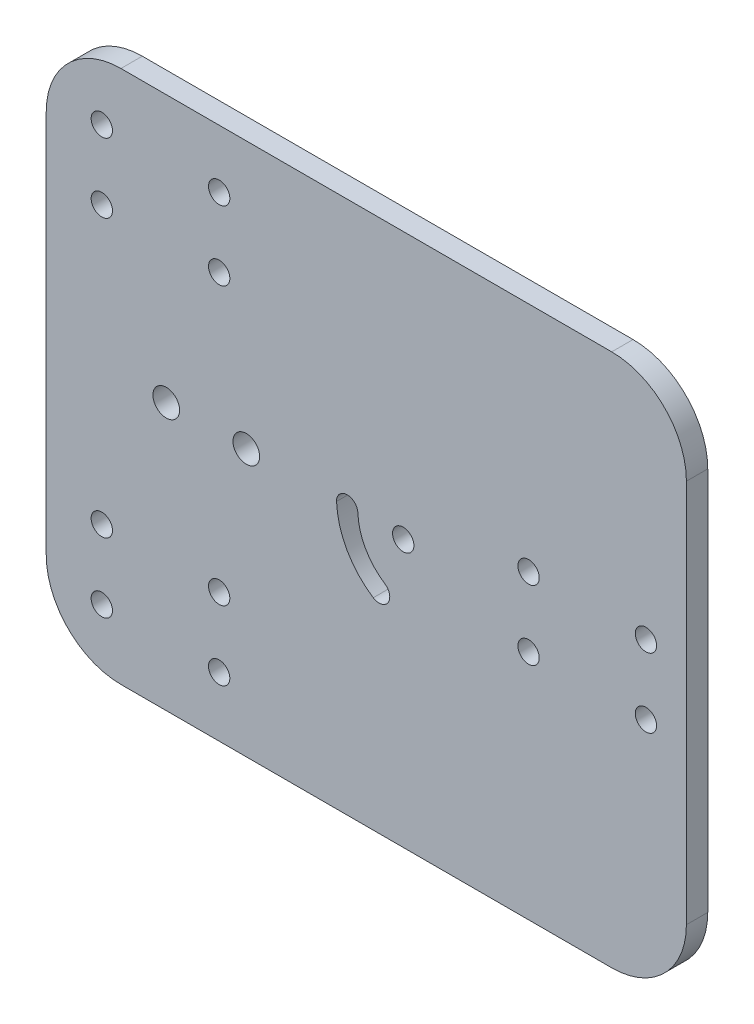
from build123d import *

# Parameters (mm, degrees)
SKETCH_1_W          = 120
SKETCH_1_H          = 100
EXTRUDE_1_DEPTH     = 4
FILLET_1_R          = 14
SKETCH_7_R          = 2.5
CUT_EXTRUDE_2_DEPTH = 5
SKETCH_14_R         = 2
CUT_EXTRUDE_3_DEPTH = 5


with BuildPart() as part:
    # 草图1 → 凸台-拉伸1 (new body)
    with BuildSketch(Plane.XY):
        with Locations((7.34439834, -11.161825726)):
            Rectangle(SKETCH_1_W, SKETCH_1_H)
    extrude(amount=EXTRUDE_1_DEPTH)

    # 圆角1
    fillet_1_edges = [part.edges().sort_by_distance(p)[0] for p in [
        (-52.65560166, 38.838174274, 2),
        (67.34439834, 38.838174274, 2),
        (67.34439834, -61.161825726, 2),
        (-52.65560166, -61.161825726, 2),
    ]]
    fillet(fillet_1_edges, radius=FILLET_1_R)

    # 草图7 → 切除-拉伸2 (cut, through all)
    with BuildSketch(Plane(origin=(0, 0, 0), x_dir=(-1, 0, 0), z_dir=(0, 0, -1))):
        with Locations((15.15560166, -11.161825726)):
            Circle(SKETCH_7_R)
        with Locations((30.15560166, -11.161825726)):
            Circle(SKETCH_7_R)
    extrude(amount=-CUT_EXTRUDE_2_DEPTH, mode=Mode.SUBTRACT)

    # 草图14 → 切除-拉伸3 (cut, through all)
    with BuildSketch(Plane(origin=(0, 0, 0), x_dir=(-1, 0, 0), z_dir=(0, 0, -1))):
        with Locations((42.240931861, -49.965268324)):
            Circle(SKETCH_14_R)
        with Locations((20.240931861, -49.965268324)):
            Circle(SKETCH_14_R)
        with Locations((42.240931861, -36.965268324)):
            Circle(SKETCH_14_R)
        with Locations((20.240931861, -36.965268324)):
            Circle(SKETCH_14_R)
        with Locations((42.240931861, 14.942073)):
            Circle(SKETCH_14_R)
        with Locations((42.240931861, 27.942073)):
            Circle(SKETCH_14_R)
        with Locations((20.240931861, 14.942073)):
            Circle(SKETCH_14_R)
        with Locations((20.240931861, 27.942073)):
            Circle(SKETCH_14_R)
        with Locations((-14.259068139, -11.161825726)):
            Circle(SKETCH_14_R)
        with Locations((-37.759068139, -17.661825726)):
            Circle(SKETCH_14_R)
        with Locations((-59.759068139, -17.661825726)):
            Circle(SKETCH_14_R)
        with Locations((-59.759068139, -4.661825726)):
            Circle(SKETCH_14_R)
        with Locations((-37.759068139, -4.661825726)):
            Circle(SKETCH_14_R)
        with BuildLine():
            ThreePointArc((-1.760462288, -11.236489328), (-3.684404538, -9.163219875), (-5.75767399, -11.087162125))
            ThreePointArc((-5.75767399, -11.087162125), (-7.203940461, -16.202085414), (-10.83494306, -20.084088387))
            ThreePointArc((-10.83494306, -20.084088387), (-11.410230768, -22.85339228), (-8.640926875, -23.428679989))
            ThreePointArc((-8.640926875, -23.428679989), (-3.720371267, -18.167981055), (-1.760462288, -11.236489328))
        make_face()
    extrude(amount=-CUT_EXTRUDE_3_DEPTH, mode=Mode.SUBTRACT)


solid = part.part
